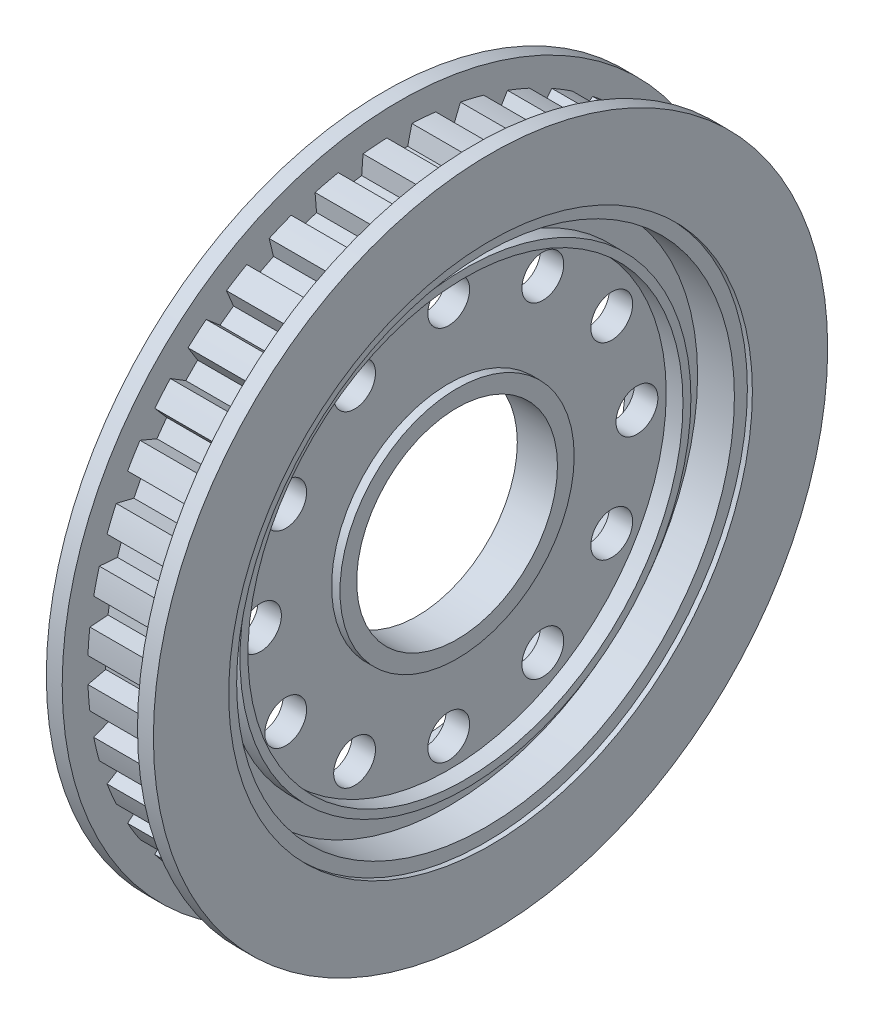
from build123d import *

# Parameters (mm, degrees)
SKIZZE2_R                       = 1.25
SCHNITT_LINEAR_AUSTRAGEN1_DEPTH = 4.9
SCHNITT_LINEAR_AUSTRAGEN2_DEPTH = 2.25
KREISMUSTER1_COUNT              = 40


with BuildPart() as part:
    # Skizze1 → Rotation1 (revolve)
    with BuildSketch(Plane.XY):
        Polygon((-3.2, 20.15), (-3.2, 15.65), (-2.9, 15.65), (-2.9, 14.875), (-0.7, 14.875), (-0.7, 13.475), (-1.7, 13.475), (-1.7, 13), (-0.7, 13), (-0.7, 7), (-1.2, 7), (-1.2, 6), (0, 6), (0, 18.625), (-2.25, 18.625), (-2.25, 20.15), align=None)
    revolve(axis=Axis((-3.753522094, 0, 0), (-1, 0, 0)))

    # Spiegeln1: part across plane


with BuildPart() as part_1:
    add(part.part)
    add(part.part.mirror(Plane(origin=(0, 0, 0), x_dir=(0, 0, 1), z_dir=(1, 0, 0))))

    # Skizze2 → Schnitt-Linear austragen1 (cut, through all)
    with BuildSketch(Plane.ZY.offset(0.7)):
        with Locations((-5.625, 9.742785793)):
            Circle(SKIZZE2_R)
        with Locations((0, 11.25)):
            Circle(SKIZZE2_R)
        with Locations((5.625, 9.742785793)):
            Circle(SKIZZE2_R)
        with Locations((9.742785793, 5.625)):
            Circle(SKIZZE2_R)
        with Locations((11.25, 0)):
            Circle(SKIZZE2_R)
        with Locations((9.742785793, -5.625)):
            Circle(SKIZZE2_R)
        with Locations((5.625, -9.742785793)):
            Circle(SKIZZE2_R)
        with Locations((0, -11.25)):
            Circle(SKIZZE2_R)
        with Locations((-5.625, -9.742785793)):
            Circle(SKIZZE2_R)
        with Locations((-9.742785793, -5.625)):
            Circle(SKIZZE2_R)
        with Locations((-11.25, 0)):
            Circle(SKIZZE2_R)
        with Locations((-9.742785793, 5.625)):
            Circle(SKIZZE2_R)
    extrude(amount=-SCHNITT_LINEAR_AUSTRAGEN1_DEPTH, mode=Mode.SUBTRACT)

    # Skizze3 → Schnitt-Linear austragen2 (cut, symmetric)
    with BuildSketch(Plane(origin=(0, 0, 0), x_dir=(0, 0, -1), z_dir=(1, 0, 0))):
        with BuildLine():
            Line((0.75, 18.609893202), (0.5, 17.55))
            Line((0.5, 17.55), (-0.5, 17.55))
            Line((-0.5, 17.55), (-0.75, 18.609893202))
            ThreePointArc((-0.75, 18.609893202), (0, 18.625), (0.75, 18.609893202))
        make_face()
    schnitt_linear_austragen2 = extrude(amount=SCHNITT_LINEAR_AUSTRAGEN2_DEPTH, both=True, mode=Mode.SUBTRACT)

    # Kreismuster1: Schnitt-Linear austragen2 ×40 about axis
    kreismuster1_axis = Axis((0, 0, 0), (1, 0, 0))
    for i in range(1, KREISMUSTER1_COUNT):
        add(schnitt_linear_austragen2.rotate(kreismuster1_axis, i * 360 / KREISMUSTER1_COUNT), mode=Mode.SUBTRACT)


solid = part_1.part
